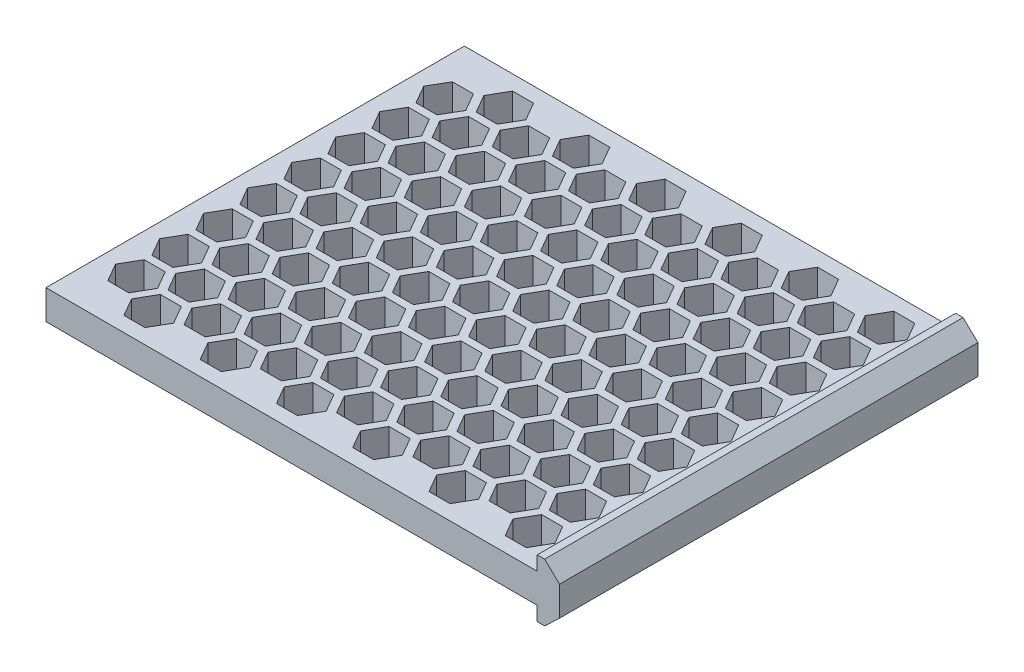
from build123d import *

# Parameters (mm, degrees)
SKETCH1_W           = 140
SKETCH1_H           = 8.1
BOSS_EXTRUDE1_DEPTH = 115
CUT_EXTRUDE3_DEPTH  = 13
SKETCH3_W           = 5
SKETCH3_H           = 8.1
CUT_EXTRUDE4_DEPTH  = 116


with BuildPart() as part:
    # Sketch1 → Boss-Extrude1 (new body)
    with BuildSketch(Plane.XY):
        with Locations((-70, 0)):
            Rectangle(SKETCH1_W, SKETCH1_H)
        Polygon((2.04, -7.95), (0, -7.95), (0, 7.95), (2.04, 7.95), (6.152414984, 4.048), (6.152414984, -4.048), align=None)
    extrude(amount=BOSS_EXTRUDE1_DEPTH)

    # Sketch2 → Cut-Extrude3 (cut, through all)
    with BuildSketch(Plane(origin=(0, 4.05, 0), x_dir=(1, 0, 0), z_dir=(0, 1, 0))):
        Polygon((-128.15473259, -20.15), (-122.381229898, -20.15), (-119.494478552, -15.15), (-122.381229898, -10.15), (-128.15473259, -10.15), (-131.041483936, -15.15), align=None)
        Polygon((-128.15473259, -32.25), (-122.381229898, -32.25), (-119.494478552, -27.25), (-122.381229898, -22.25), (-128.15473259, -22.25), (-131.041483936, -27.25), align=None)
        Polygon((-128.15473259, -44.35), (-122.381229898, -44.35), (-119.494478552, -39.35), (-122.381229898, -34.35), (-128.15473259, -34.35), (-131.041483936, -39.35), align=None)
        Polygon((-128.15473259, -56.45), (-122.381229898, -56.45), (-119.494478552, -51.45), (-122.381229898, -46.45), (-128.15473259, -46.45), (-131.041483936, -51.45), align=None)
        Polygon((-128.15473259, -68.55), (-122.381229898, -68.55), (-119.494478552, -63.55), (-122.381229898, -58.55), (-128.15473259, -58.55), (-131.041483936, -63.55), align=None)
        Polygon((-128.15473259, -80.65), (-122.381229898, -80.65), (-119.494478552, -75.65), (-122.381229898, -70.65), (-128.15473259, -70.65), (-131.041483936, -75.65), align=None)
        Polygon((-128.15473259, -92.75), (-122.381229898, -92.75), (-119.494478552, -87.75), (-122.381229898, -82.75), (-128.15473259, -82.75), (-131.041483936, -87.75), align=None)
        Polygon((-128.15473259, -104.85), (-122.381229898, -104.85), (-119.494478552, -99.85), (-122.381229898, -94.85), (-128.15473259, -94.85), (-131.041483936, -99.85), align=None)
        Polygon((-117.675825204, -110.9), (-111.902322512, -110.9), (-109.015571166, -105.9), (-111.902322512, -100.9), (-117.675825204, -100.9), (-120.56257655, -105.9), align=None)
        Polygon((-117.675825204, -98.8), (-111.902322512, -98.8), (-109.015571166, -93.8), (-111.902322512, -88.8), (-117.675825204, -88.8), (-120.56257655, -93.8), align=None)
        Polygon((-117.675825204, -86.7), (-111.902322512, -86.7), (-109.015571166, -81.7), (-111.902322512, -76.7), (-117.675825204, -76.7), (-120.56257655, -81.7), align=None)
        Polygon((-117.675825204, -74.6), (-111.902322512, -74.6), (-109.015571166, -69.6), (-111.902322512, -64.6), (-117.675825204, -64.6), (-120.56257655, -69.6), align=None)
        Polygon((-117.675825204, -62.5), (-111.902322512, -62.5), (-109.015571166, -57.5), (-111.902322512, -52.5), (-117.675825204, -52.5), (-120.56257655, -57.5), align=None)
        Polygon((-117.675825204, -50.4), (-111.902322512, -50.4), (-109.015571166, -45.4), (-111.902322512, -40.4), (-117.675825204, -40.4), (-120.56257655, -45.4), align=None)
        Polygon((-117.675825204, -38.3), (-111.902322512, -38.3), (-109.015571166, -33.3), (-111.902322512, -28.3), (-117.675825204, -28.3), (-120.56257655, -33.3), align=None)
        Polygon((-117.675825204, -26.2), (-111.902322512, -26.2), (-109.015571166, -21.2), (-111.902322512, -16.2), (-117.675825204, -16.2), (-120.56257655, -21.2), align=None)
        Polygon((-117.675825204, -14.1), (-111.902322512, -14.1), (-109.015571166, -9.1), (-111.902322512, -4.1), (-117.675825204, -4.1), (-120.56257655, -9.1), align=None)
        Polygon((-107.196917818, -20.15), (-101.423415126, -20.15), (-98.53666378, -15.15), (-101.423415126, -10.15), (-107.196917818, -10.15), (-110.083669164, -15.15), align=None)
        Polygon((-107.196917818, -32.25), (-101.423415126, -32.25), (-98.53666378, -27.25), (-101.423415126, -22.25), (-107.196917818, -22.25), (-110.083669164, -27.25), align=None)
        Polygon((-107.196917818, -44.35), (-101.423415126, -44.35), (-98.53666378, -39.35), (-101.423415126, -34.35), (-107.196917818, -34.35), (-110.083669164, -39.35), align=None)
        Polygon((-107.196917818, -56.45), (-101.423415126, -56.45), (-98.53666378, -51.45), (-101.423415126, -46.45), (-107.196917818, -46.45), (-110.083669164, -51.45), align=None)
        Polygon((-107.196917818, -80.65), (-101.423415126, -80.65), (-98.53666378, -75.65), (-101.423415126, -70.65), (-107.196917818, -70.65), (-110.083669164, -75.65), align=None)
        Polygon((-107.196917818, -92.75), (-101.423415126, -92.75), (-98.53666378, -87.75), (-101.423415126, -82.75), (-107.196917818, -82.75), (-110.083669164, -87.75), align=None)
        Polygon((-107.196917818, -104.85), (-101.423415126, -104.85), (-98.53666378, -99.85), (-101.423415126, -94.85), (-107.196917818, -94.85), (-110.083669164, -99.85), align=None)
        Polygon((-96.718010432, -98.8), (-90.94450774, -98.8), (-88.057756394, -93.8), (-90.94450774, -88.8), (-96.718010432, -88.8), (-99.604761778, -93.8), align=None)
        Polygon((-96.718010432, -110.9), (-90.94450774, -110.9), (-88.057756394, -105.9), (-90.94450774, -100.9), (-96.718010432, -100.9), (-99.604761778, -105.9), align=None)
        Polygon((-96.718010432, -86.7), (-90.94450774, -86.7), (-88.057756394, -81.7), (-90.94450774, -76.7), (-96.718010432, -76.7), (-99.604761778, -81.7), align=None)
        Polygon((-96.718010432, -74.6), (-90.94450774, -74.6), (-88.057756394, -69.6), (-90.94450774, -64.6), (-96.718010432, -64.6), (-99.604761778, -69.6), align=None)
        Polygon((-96.718010432, -62.5), (-90.94450774, -62.5), (-88.057756394, -57.5), (-90.94450774, -52.5), (-96.718010432, -52.5), (-99.604761778, -57.5), align=None)
        Polygon((-96.718010432, -50.4), (-90.94450774, -50.4), (-88.057756394, -45.4), (-90.94450774, -40.4), (-96.718010432, -40.4), (-99.604761778, -45.4), align=None)
        Polygon((-96.718010432, -38.3), (-90.94450774, -38.3), (-88.057756394, -33.3), (-90.94450774, -28.3), (-96.718010432, -28.3), (-99.604761778, -33.3), align=None)
        Polygon((-96.718010432, -26.2), (-90.94450774, -26.2), (-88.057756394, -21.2), (-90.94450774, -16.2), (-96.718010432, -16.2), (-99.604761778, -21.2), align=None)
        Polygon((-96.718010432, -14.1), (-90.94450774, -14.1), (-88.057756394, -9.1), (-90.94450774, -4.1), (-96.718010432, -4.1), (-99.604761778, -9.1), align=None)
        Polygon((-86.239103046, -20.15), (-80.465600355, -20.15), (-77.578849009, -15.15), (-80.465600355, -10.15), (-86.239103046, -10.15), (-89.125854392, -15.15), align=None)
        Polygon((-86.239103046, -32.25), (-80.465600355, -32.25), (-77.578849009, -27.25), (-80.465600355, -22.25), (-86.239103046, -22.25), (-89.125854392, -27.25), align=None)
        Polygon((-86.239103046, -44.35), (-80.465600355, -44.35), (-77.578849009, -39.35), (-80.465600355, -34.35), (-86.239103046, -34.35), (-89.125854392, -39.35), align=None)
        Polygon((-86.239103046, -56.45), (-80.465600355, -56.45), (-77.578849009, -51.45), (-80.465600355, -46.45), (-86.239103046, -46.45), (-89.125854392, -51.45), align=None)
        Polygon((-86.239103046, -68.55), (-80.465600355, -68.55), (-77.578849009, -63.55), (-80.465600355, -58.55), (-86.239103046, -58.55), (-89.125854392, -63.55), align=None)
        Polygon((-86.239103046, -80.65), (-80.465600355, -80.65), (-77.578849009, -75.65), (-80.465600355, -70.65), (-86.239103046, -70.65), (-89.125854392, -75.65), align=None)
        Polygon((-86.239103046, -92.75), (-80.465600355, -92.75), (-77.578849009, -87.75), (-80.465600355, -82.75), (-86.239103046, -82.75), (-89.125854392, -87.75), align=None)
        Polygon((-86.239103046, -104.85), (-80.465600355, -104.85), (-77.578849009, -99.85), (-80.465600355, -94.85), (-86.239103046, -94.85), (-89.125854392, -99.85), align=None)
        Polygon((-75.760195661, -110.9), (-69.986692969, -110.9), (-67.099941623, -105.9), (-69.986692969, -100.9), (-75.760195661, -100.9), (-78.646947007, -105.9), align=None)
        Polygon((-75.760195661, -98.8), (-69.986692969, -98.8), (-67.099941623, -93.8), (-69.986692969, -88.8), (-75.760195661, -88.8), (-78.646947007, -93.8), align=None)
        Polygon((-75.760195661, -86.7), (-69.986692969, -86.7), (-67.099941623, -81.7), (-69.986692969, -76.7), (-75.760195661, -76.7), (-78.646947007, -81.7), align=None)
        Polygon((-75.760195661, -74.6), (-69.986692969, -74.6), (-67.099941623, -69.6), (-69.986692969, -64.6), (-75.760195661, -64.6), (-78.646947007, -69.6), align=None)
        Polygon((-75.760195661, -62.5), (-69.986692969, -62.5), (-67.099941623, -57.5), (-69.986692969, -52.5), (-75.760195661, -52.5), (-78.646947007, -57.5), align=None)
        Polygon((-75.760195661, -50.4), (-69.986692969, -50.4), (-67.099941623, -45.4), (-69.986692969, -40.4), (-75.760195661, -40.4), (-78.646947007, -45.4), align=None)
        Polygon((-75.760195661, -38.3), (-69.986692969, -38.3), (-67.099941623, -33.3), (-69.986692969, -28.3), (-75.760195661, -28.3), (-78.646947007, -33.3), align=None)
        Polygon((-75.760195661, -26.2), (-69.986692969, -26.2), (-67.099941623, -21.2), (-69.986692969, -16.2), (-75.760195661, -16.2), (-78.646947007, -21.2), align=None)
        Polygon((-75.760195661, -14.1), (-69.986692969, -14.1), (-67.099941623, -9.1), (-69.986692969, -4.1), (-75.760195661, -4.1), (-78.646947007, -9.1), align=None)
        Polygon((-65.281288275, -20.15), (-59.507785583, -20.15), (-56.621034237, -15.15), (-59.507785583, -10.15), (-65.281288275, -10.15), (-68.168039621, -15.15), align=None)
        Polygon((-65.281288275, -32.25), (-59.507785583, -32.25), (-56.621034237, -27.25), (-59.507785583, -22.25), (-65.281288275, -22.25), (-68.168039621, -27.25), align=None)
        Polygon((-65.281288275, -44.35), (-59.507785583, -44.35), (-56.621034237, -39.35), (-59.507785583, -34.35), (-65.281288275, -34.35), (-68.168039621, -39.35), align=None)
        Polygon((-65.281288275, -56.45), (-59.507785583, -56.45), (-56.621034237, -51.45), (-59.507785583, -46.45), (-65.281288275, -46.45), (-68.168039621, -51.45), align=None)
        Polygon((-65.281288275, -68.55), (-59.507785583, -68.55), (-56.621034237, -63.55), (-59.507785583, -58.55), (-65.281288275, -58.55), (-68.168039621, -63.55), align=None)
        Polygon((-65.281288275, -80.65), (-59.507785583, -80.65), (-56.621034237, -75.65), (-59.507785583, -70.65), (-65.281288275, -70.65), (-68.168039621, -75.65), align=None)
        Polygon((-65.281288275, -92.75), (-59.507785583, -92.75), (-56.621034237, -87.75), (-59.507785583, -82.75), (-65.281288275, -82.75), (-68.168039621, -87.75), align=None)
        Polygon((-65.281288275, -104.85), (-59.507785583, -104.85), (-56.621034237, -99.85), (-59.507785583, -94.85), (-65.281288275, -94.85), (-68.168039621, -99.85), align=None)
        Polygon((-54.802380889, -110.9), (-49.028878197, -110.9), (-46.142126851, -105.9), (-49.028878197, -100.9), (-54.802380889, -100.9), (-57.689132235, -105.9), align=None)
        Polygon((-54.802380889, -98.8), (-49.028878197, -98.8), (-46.142126851, -93.8), (-49.028878197, -88.8), (-54.802380889, -88.8), (-57.689132235, -93.8), align=None)
        Polygon((-54.802380889, -86.7), (-49.028878197, -86.7), (-46.142126851, -81.7), (-49.028878197, -76.7), (-54.802380889, -76.7), (-57.689132235, -81.7), align=None)
        Polygon((-44.323473503, -92.75), (-38.549970811, -92.75), (-35.663219465, -87.75), (-38.549970811, -82.75), (-44.323473503, -82.75), (-47.210224849, -87.75), align=None)
        Polygon((-44.323473503, -80.65), (-38.549970811, -80.65), (-35.663219465, -75.65), (-38.549970811, -70.65), (-44.323473503, -70.65), (-47.210224849, -75.65), align=None)
        Polygon((-44.323473503, -104.85), (-38.549970811, -104.85), (-35.663219465, -99.85), (-38.549970811, -94.85), (-44.323473503, -94.85), (-47.210224849, -99.85), align=None)
        Polygon((-44.323473503, -68.55), (-38.549970811, -68.55), (-35.663219465, -63.55), (-38.549970811, -58.55), (-44.323473503, -58.55), (-47.210224849, -63.55), align=None)
        Polygon((-54.802380889, -62.5), (-49.028878197, -62.5), (-46.142126851, -57.5), (-49.028878197, -52.5), (-54.802380889, -52.5), (-57.689132235, -57.5), align=None)
        Polygon((-44.323473503, -56.45), (-38.549970811, -56.45), (-35.663219465, -51.45), (-38.549970811, -46.45), (-44.323473503, -46.45), (-47.210224849, -51.45), align=None)
        Polygon((-54.802380889, -50.4), (-49.028878197, -50.4), (-46.142126851, -45.4), (-49.028878197, -40.4), (-54.802380889, -40.4), (-57.689132235, -45.4), align=None)
        Polygon((-44.323473503, -44.35), (-38.549970811, -44.35), (-35.663219465, -39.35), (-38.549970811, -34.35), (-44.323473503, -34.35), (-47.210224849, -39.35), align=None)
        Polygon((-54.802380889, -38.3), (-49.028878197, -38.3), (-46.142126851, -33.3), (-49.028878197, -28.3), (-54.802380889, -28.3), (-57.689132235, -33.3), align=None)
        Polygon((-44.323473503, -32.25), (-38.549970811, -32.25), (-35.663219465, -27.25), (-38.549970811, -22.25), (-44.323473503, -22.25), (-47.210224849, -27.25), align=None)
        Polygon((-54.802380889, -26.2), (-49.028878197, -26.2), (-46.142126851, -21.2), (-49.028878197, -16.2), (-54.802380889, -16.2), (-57.689132235, -21.2), align=None)
        Polygon((-54.802380889, -14.1), (-49.028878197, -14.1), (-46.142126851, -9.1), (-49.028878197, -4.1), (-54.802380889, -4.1), (-57.689132235, -9.1), align=None)
        Polygon((-33.844566118, -14.1), (-28.071063426, -14.1), (-25.18431208, -9.1), (-28.071063426, -4.1), (-33.844566118, -4.1), (-36.731317463, -9.1), align=None)
        Polygon((-33.844566118, -26.2), (-28.071063426, -26.2), (-25.18431208, -21.2), (-28.071063426, -16.2), (-33.844566118, -16.2), (-36.731317463, -21.2), align=None)
        Polygon((-33.844566118, -38.3), (-28.071063426, -38.3), (-25.18431208, -33.3), (-28.071063426, -28.3), (-33.844566118, -28.3), (-36.731317463, -33.3), align=None)
        Polygon((-33.844566118, -50.4), (-28.071063426, -50.4), (-25.18431208, -45.4), (-28.071063426, -40.4), (-33.844566118, -40.4), (-36.731317463, -45.4), align=None)
        Polygon((-33.844566118, -62.5), (-28.071063426, -62.5), (-25.18431208, -57.5), (-28.071063426, -52.5), (-33.844566118, -52.5), (-36.731317463, -57.5), align=None)
        Polygon((-33.844566118, -74.6), (-28.071063426, -74.6), (-25.18431208, -69.6), (-28.071063426, -64.6), (-33.844566118, -64.6), (-36.731317463, -69.6), align=None)
        Polygon((-33.844566118, -98.8), (-28.071063426, -98.8), (-25.18431208, -93.8), (-28.071063426, -88.8), (-33.844566118, -88.8), (-36.731317463, -93.8), align=None)
        Polygon((-33.844566118, -110.9), (-28.071063426, -110.9), (-25.18431208, -105.9), (-28.071063426, -100.9), (-33.844566118, -100.9), (-36.731317463, -105.9), align=None)
        Polygon((-23.365658732, -104.85), (-17.59215604, -104.85), (-14.705404694, -99.85), (-17.59215604, -94.85), (-23.365658732, -94.85), (-26.252410078, -99.85), align=None)
        Polygon((-23.365658732, -92.75), (-17.59215604, -92.75), (-14.705404694, -87.75), (-17.59215604, -82.75), (-23.365658732, -82.75), (-26.252410078, -87.75), align=None)
        Polygon((-23.365658732, -80.65), (-17.59215604, -80.65), (-14.705404694, -75.65), (-17.59215604, -70.65), (-23.365658732, -70.65), (-26.252410078, -75.65), align=None)
        Polygon((-23.365658732, -68.55), (-17.59215604, -68.55), (-14.705404694, -63.55), (-17.59215604, -58.55), (-23.365658732, -58.55), (-26.252410078, -63.55), align=None)
        Polygon((-23.365658732, -56.45), (-17.59215604, -56.45), (-14.705404694, -51.45), (-17.59215604, -46.45), (-23.365658732, -46.45), (-26.252410078, -51.45), align=None)
        Polygon((-23.365658732, -32.25), (-17.59215604, -32.25), (-14.705404694, -27.25), (-17.59215604, -22.25), (-23.365658732, -22.25), (-26.252410078, -27.25), align=None)
        Polygon((-23.365658732, -20.15), (-17.59215604, -20.15), (-14.705404694, -15.15), (-17.59215604, -10.15), (-23.365658732, -10.15), (-26.252410078, -15.15), align=None)
        Polygon((-12.886751346, -14.1), (-7.113248654, -14.1), (-4.226497308, -9.1), (-7.113248654, -4.1), (-12.886751346, -4.1), (-15.773502692, -9.1), align=None)
        Polygon((-12.886751346, -26.2), (-7.113248654, -26.2), (-4.226497308, -21.2), (-7.113248654, -16.2), (-12.886751346, -16.2), (-15.773502692, -21.2), align=None)
        Polygon((-12.886751346, -38.3), (-7.113248654, -38.3), (-4.226497308, -33.3), (-7.113248654, -28.3), (-12.886751346, -28.3), (-15.773502692, -33.3), align=None)
        Polygon((-12.886751346, -50.4), (-7.113248654, -50.4), (-4.226497308, -45.4), (-7.113248654, -40.4), (-12.886751346, -40.4), (-15.773502692, -45.4), align=None)
        Polygon((-12.886751346, -62.5), (-7.113248654, -62.5), (-4.226497308, -57.5), (-7.113248654, -52.5), (-12.886751346, -52.5), (-15.773502692, -57.5), align=None)
        Polygon((-12.886751346, -74.6), (-7.113248654, -74.6), (-4.226497308, -69.6), (-7.113248654, -64.6), (-12.886751346, -64.6), (-15.773502692, -69.6), align=None)
        Polygon((-12.886751346, -86.7), (-7.113248654, -86.7), (-4.226497308, -81.7), (-7.113248654, -76.7), (-12.886751346, -76.7), (-15.773502692, -81.7), align=None)
        Polygon((-12.886751346, -98.8), (-7.113248654, -98.8), (-4.226497308, -93.8), (-7.113248654, -88.8), (-12.886751346, -88.8), (-15.773502692, -93.8), align=None)
        Polygon((-12.886751346, -110.9), (-7.113248654, -110.9), (-4.226497308, -105.9), (-7.113248654, -100.9), (-12.886751346, -100.9), (-15.773502692, -105.9), align=None)
        Polygon((-107.196917818, -68.55), (-101.423415126, -68.55), (-98.53666378, -63.55), (-101.423415126, -58.55), (-107.196917818, -58.55), (-110.083669164, -63.55), align=None)
        Polygon((-54.802380889, -74.6), (-49.028878197, -74.6), (-46.142126851, -69.6), (-49.028878197, -64.6), (-54.802380889, -64.6), (-57.689132235, -69.6), align=None)
        Polygon((-44.323473503, -20.15), (-38.549970811, -20.15), (-35.663219465, -15.15), (-38.549970811, -10.15), (-44.323473503, -10.15), (-47.210224849, -15.15), align=None)
        Polygon((-23.365658732, -44.35), (-17.59215604, -44.35), (-14.705404694, -39.35), (-17.59215604, -34.35), (-23.365658732, -34.35), (-26.252410078, -39.35), align=None)
        Polygon((-33.844566118, -86.7), (-28.071063426, -86.7), (-25.18431208, -81.7), (-28.071063426, -76.7), (-33.844566118, -76.7), (-36.731317463, -81.7), align=None)
    extrude(amount=-CUT_EXTRUDE3_DEPTH, mode=Mode.SUBTRACT)

    # Sketch3 → Cut-Extrude4 (cut, through all)
    with BuildSketch(Plane.XY.offset(115)):
        with Locations((-137.5, 0)):
            Rectangle(SKETCH3_W, SKETCH3_H)
    extrude(amount=-CUT_EXTRUDE4_DEPTH, mode=Mode.SUBTRACT)


solid = part.part
